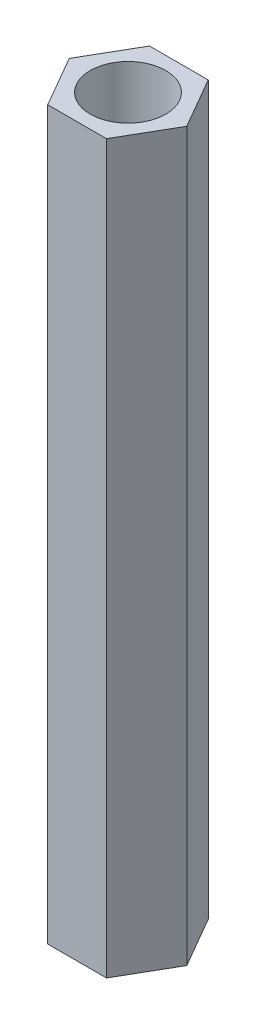
from build123d import *

# Parameters (mm, degrees)
EXTRUDE_1_DEPTH     = 50
SKETCH_2_R          = 2.6
CUT_EXTRUDE_1_DEPTH = 51
SKETCH_3_R          = 2.6
EXTRUDE_2_DEPTH     = 30


with BuildPart() as part:
    # 草图1 → 凸台-拉伸1 (new body)
    with BuildSketch(Plane(origin=(0, 0, 0), x_dir=(1, 0, 0), z_dir=(0, 1, 0))):
        Polygon((4.041451884, 0), (2.020725942, 3.5), (-2.020725942, 3.5), (-4.041451884, 0), (-2.020725942, -3.5), (2.020725942, -3.5), align=None)
    extrude(amount=EXTRUDE_1_DEPTH)

    # 草图2 → 切除-拉伸1 (cut, through all)
    with BuildSketch(Plane(origin=(0, 50, 0), x_dir=(1, 0, 0), z_dir=(0, 1, 0))):
        Circle(SKETCH_2_R)
    extrude(amount=-CUT_EXTRUDE_1_DEPTH, mode=Mode.SUBTRACT)

    # 草图3 → 凸台-拉伸2 (add)
    with BuildSketch(Plane(origin=(0, 10, 0), x_dir=(-1, 0, 0), z_dir=(0, -1, 0))):
        Circle(SKETCH_3_R)
    extrude(amount=-EXTRUDE_2_DEPTH)


solid = part.part
